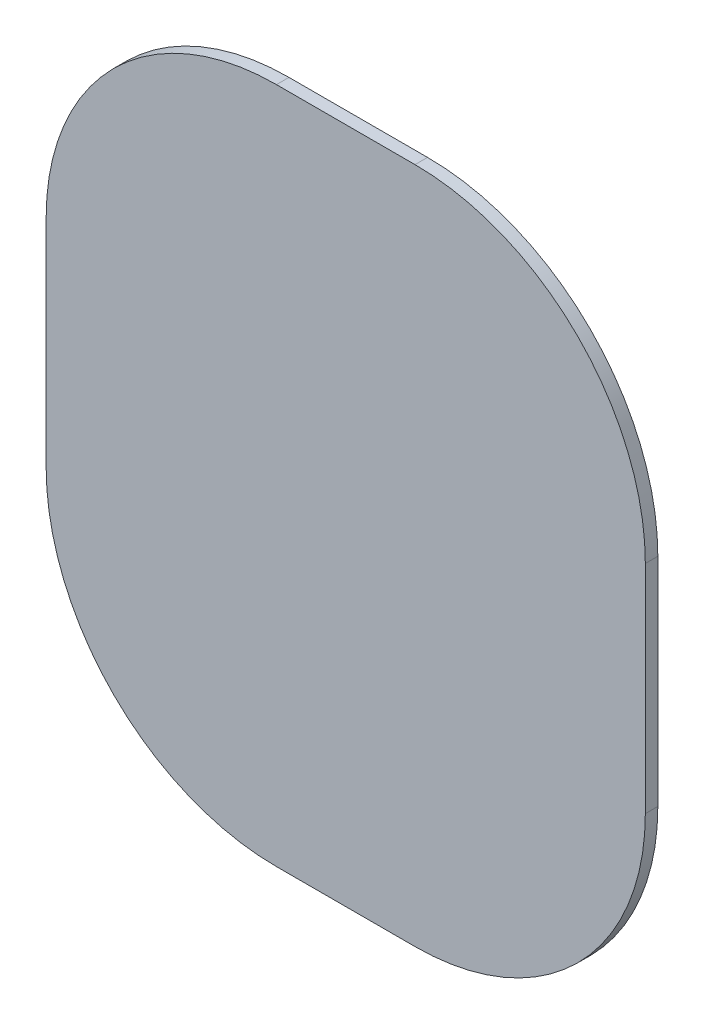
from build123d import *

# Parameters (mm, degrees)
BOSS_EXTRUDE3_DEPTH = 6.35


with BuildPart() as part:
    # Sketch14 → Boss-Extrude3 (new body)
    with BuildSketch(Plane.XY.offset(8.89)):
        with BuildLine():
            Line((198.236322144, 213.469330483), (127.925881088, 213.469330483))
            ThreePointArc((127.925881088, 213.469330483), (45.307524774, 179.247686797), (11.085881088, 96.629330483))
            Line((11.085881088, 96.629330483), (11.085881088, -13.285692494))
            ThreePointArc((11.085881088, -13.285692494), (45.307524774, -95.904048808), (127.925881088, -130.125692494))
            Line((127.925881088, -130.125692494), (198.236322144, -130.125692494))
            ThreePointArc((198.236322144, -130.125692494), (280.854678457, -95.904048808), (315.076322144, -13.285692494))
            Line((315.076322144, -13.285692494), (315.076322144, 96.629330483))
            ThreePointArc((315.076322144, 96.629330483), (280.854678457, 179.247686797), (198.236322144, 213.469330483))
        make_face()
    extrude(amount=BOSS_EXTRUDE3_DEPTH)


solid = part.part
